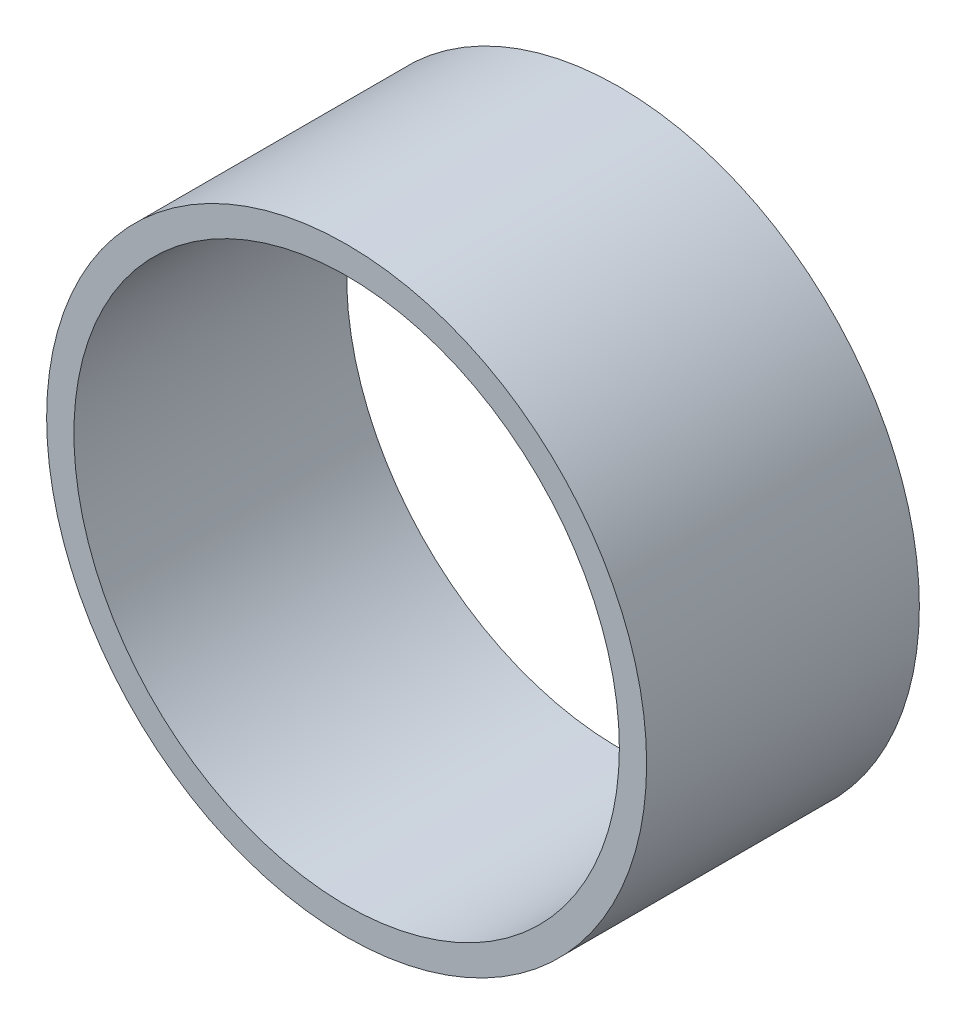
from build123d import *

# Parameters (mm, degrees)
SKETCH1_R           = 5.5
SKETCH1_R_2         = 5
BOSS_EXTRUDE1_DEPTH = 5


with BuildPart() as part:
    # Sketch1 → Boss-Extrude1 (new body)
    with BuildSketch(Plane.XY):
        Circle(SKETCH1_R)
        Circle(SKETCH1_R_2, mode=Mode.SUBTRACT)
    extrude(amount=BOSS_EXTRUDE1_DEPTH)


solid = part.part
